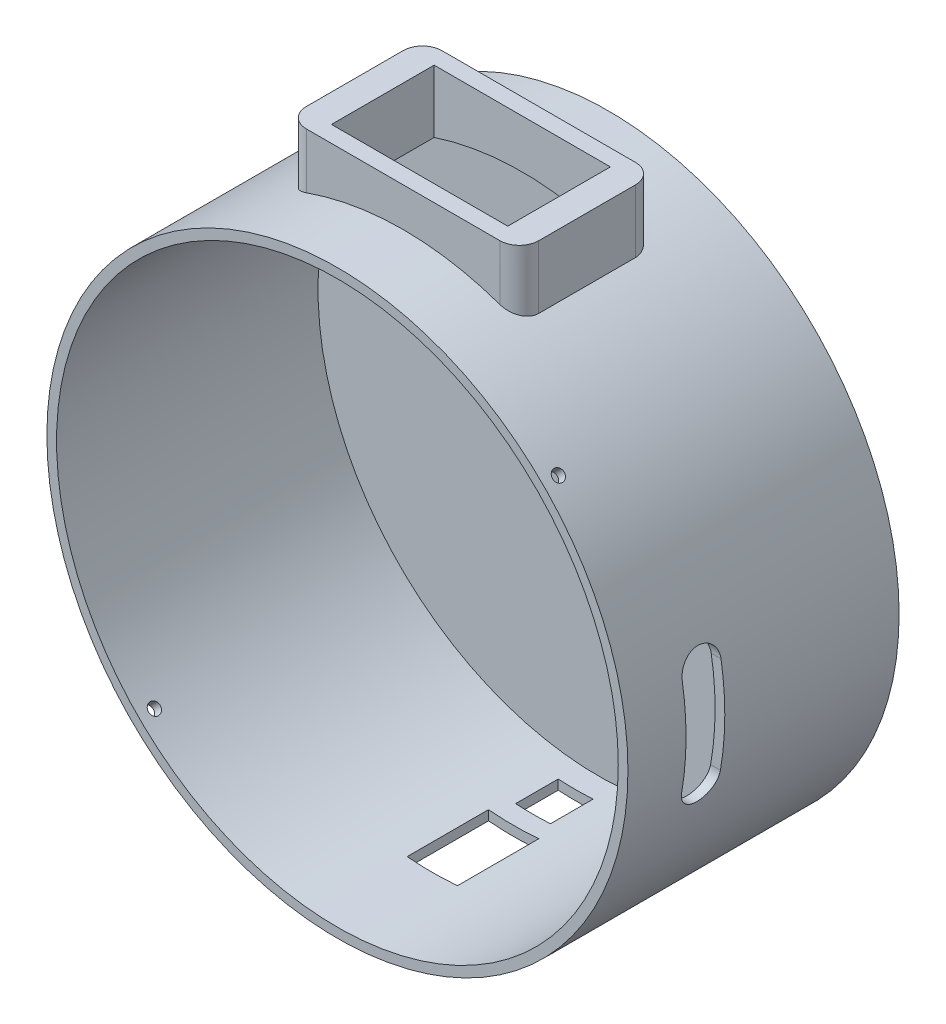
from build123d import *

# Parameters (mm, degrees)
SZKIC1_R                    = 75
DODANIE_WYCI_GNI_CIE1_DEPTH = 70
SKORUPA1_T                  = -2.5
SZKIC3_W                    = 13
SZKIC3_H                    = 21
WYTNIJ_WYCI_GNI_CIE1_DEPTH  = 60
SZKIC4_W                    = 9
SZKIC4_H                    = 11
WYTNIJ_WYCI_GNI_CIE2_DEPTH  = 60
DODANIE_WYCI_GNI_CIE2_REACH = 192.066
SZKIC7_W                    = 60
SZKIC7_H                    = 35
SZKIC8_W                    = 45.5
SZKIC8_H                    = 26.5
WYTNIJ_WYCI_GNI_CIE4_DEPTH  = 30
ZAOKR_GLENIE1_R             = 5
WYTNIJ_WYCI_GNI_CIE5_DEPTH  = 14
SZKIC10_R                   = 1.5
WYTNIJ_WYCI_GNI_CIE6_DEPTH  = 10
SZYK_KO_OWY1_COUNT          = 4


with BuildPart() as part:
    # Szkic1 → Dodanie-wyciągnięcie1 (new body)
    with BuildSketch(Plane.XY):
        Circle(SZKIC1_R)
    extrude(amount=DODANIE_WYCI_GNI_CIE1_DEPTH)

    # Skorupa1
    skorupa1_openings = [part.faces().sort_by_distance(p)[0] for p in [
        (0, 0, 70),
    ]]
    offset(amount=SKORUPA1_T, openings=skorupa1_openings, kind=Kind.INTERSECTION)

    # Szkic3 → Wytnij-wyciągnięcie1 (cut)
    with BuildSketch(Plane(origin=(0, -75, 0), x_dir=(-1, 0, 0), z_dir=(0, -1, 0))):
        with Locations((0, -35)):
            Rectangle(SZKIC3_W, SZKIC3_H)
    extrude(amount=-WYTNIJ_WYCI_GNI_CIE1_DEPTH, mode=Mode.SUBTRACT)

    # Szkic4 → Wytnij-wyciągnięcie2 (cut)
    with BuildSketch(Plane(origin=(0, -75, 0), x_dir=(-1, 0, 0), z_dir=(0, -1, 0))):
        with Locations((0, -14)):
            Rectangle(SZKIC4_W, SZKIC4_H)
    extrude(amount=-WYTNIJ_WYCI_GNI_CIE2_DEPTH, mode=Mode.SUBTRACT)

    # Szkic7 → Dodanie-wyciągnięcie2 (add, up to next)
    with BuildSketch(Plane(origin=(0, 85, 0), x_dir=(-1, 0, 0), z_dir=(0, -1, 0)), mode=Mode.PRIVATE) as dodanie_wyci_gni_cie2_sk1:
        with Locations((0, -35.532003496)):
            Rectangle(SZKIC7_W, SZKIC7_H)
    dodanie_wyci_gni_cie2_tool1 = extrude(dodanie_wyci_gni_cie2_sk1.sketch, amount=DODANIE_WYCI_GNI_CIE2_REACH, mode=Mode.PRIVATE) - part.part
    add(dodanie_wyci_gni_cie2_tool1.solids().sort_by_distance((0, 85, 35.532003))[0])

    # Szkic8 → Wytnij-wyciągnięcie4 (cut)
    with BuildSketch(Plane(origin=(0, 85, 0), x_dir=(1, 0, 0), z_dir=(0, 1, 0))):
        with Locations((0, -35.532003496)):
            Rectangle(SZKIC8_W, SZKIC8_H)
    extrude(amount=-WYTNIJ_WYCI_GNI_CIE4_DEPTH, mode=Mode.SUBTRACT)

    # Zaokrąglenie1
    zaokr_glenie1_edges = [part.edges().sort_by_distance(p)[0] for p in [
        (30, 76.869317712, 53.032003496),
        (30, 76.869317712, 18.032003496),
        (-30, 76.869317712, 53.032003496),
        (-30, 76.869317712, 18.032003496),
    ]]
    fillet(zaokr_glenie1_edges, radius=ZAOKR_GLENIE1_R)

    # Szkic9 → Wytnij-wyciągnięcie5 (cut)
    with BuildSketch(Plane(origin=(75, 0, 0), x_dir=(0, 0, -1), z_dir=(1, 0, 0))):
        with BuildLine():
            Line((-55, -12.979686846), (-55, 12.020313154))
            ThreePointArc((-55, 12.020313154), (-50, 17.020313154), (-45, 12.020313154))
            Line((-45, 12.020313154), (-45, -12.979686846))
            ThreePointArc((-45, -12.979686846), (-50, -17.979686846), (-55, -12.979686846))
        make_face()
    extrude(amount=-WYTNIJ_WYCI_GNI_CIE5_DEPTH, mode=Mode.SUBTRACT)

    # Szkic10 → Wytnij-wyciągnięcie6 (cut)
    with BuildSketch(Plane(origin=(53.033008589, 53.033008589, 0), x_dir=(0, 0, -1), z_dir=(0.7071067811865512, 0.7071067811865438, 0))):
        with Locations((-66, 0)):
            Circle(SZKIC10_R)
    wytnij_wyci_gni_cie6 = extrude(amount=-WYTNIJ_WYCI_GNI_CIE6_DEPTH, mode=Mode.SUBTRACT)

    # Szyk kołowy1: Wytnij-wyciągnięcie6 ×4 about axis
    szyk_ko_owy1_axis = Axis((0, 0, 70), (0, 0, -1))
    for i in range(1, SZYK_KO_OWY1_COUNT):
        add(wytnij_wyci_gni_cie6.rotate(szyk_ko_owy1_axis, i * 360 / SZYK_KO_OWY1_COUNT), mode=Mode.SUBTRACT)


solid = part.part
